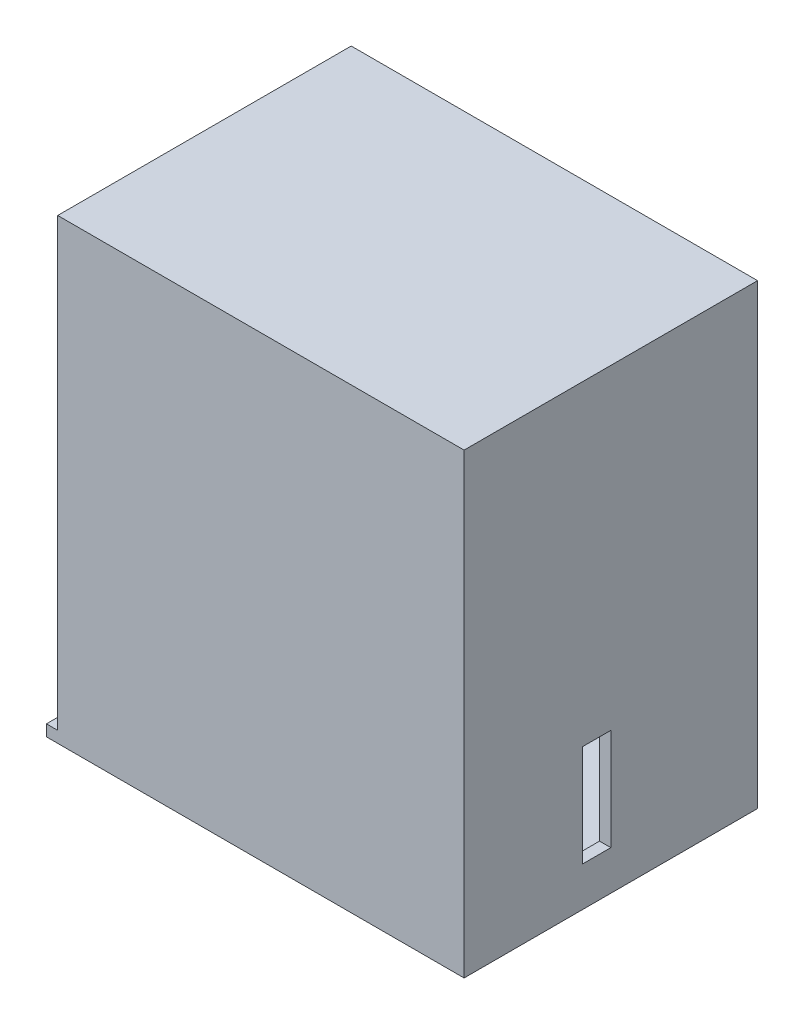
from build123d import *

# Parameters (mm, degrees)
SKIZZE1_W                       = 70
SKIZZE1_H                       = 77
AUFSATZ_LINEAR_AUSTRAGEN1_DEPTH = 2
SKIZZE2_W                       = 52
SKIZZE2_H                       = 77
SKIZZE2_W_2                     = 5
SKIZZE2_H_2                     = 18
AUFSATZ_LINEAR_AUSTRAGEN2_DEPTH = 2
SKIZZE3_W                       = 74
SKIZZE3_H                       = 52
SKIZZE3_W_2                     = 28
SKIZZE3_H_2                     = 6
AUFSATZ_LINEAR_AUSTRAGEN3_DEPTH = 2
SKIZZE9_W                       = 72
SKIZZE9_H                       = 52
AUFSATZ_LINEAR_AUSTRAGEN7_DEPTH = 2


with BuildPart() as part:
    # Skizze1 → Aufsatz-Linear austragen1 (new body)
    with BuildSketch(Plane.XY):
        with Locations((-44.446663724, -34.290378007)):
            Rectangle(SKIZZE1_W, SKIZZE1_H)
    extrude(amount=AUFSATZ_LINEAR_AUSTRAGEN1_DEPTH)

    # Skizze2 → Aufsatz-Linear austragen2 (add)
    with BuildSketch(Plane(origin=(-9.446663724, 0, 0), x_dir=(0, 0, -1), z_dir=(1, 0, 0))):
        with Locations((24, -34.290378007)):
            Rectangle(SKIZZE2_W, SKIZZE2_H)
        with Locations((21.5, -58.790378007)):
            Rectangle(SKIZZE2_W_2, SKIZZE2_H_2, mode=Mode.SUBTRACT)
    extrude(amount=AUFSATZ_LINEAR_AUSTRAGEN2_DEPTH)

    # Skizze3 → Aufsatz-Linear austragen3 (add)
    with BuildSketch(Plane.XZ.offset(72.790378007)):
        with Locations((-44.446663724, -24)):
            Rectangle(SKIZZE3_W, SKIZZE3_H)
        with Locations((-59.397812879, -32)):
            Rectangle(SKIZZE3_W_2, SKIZZE3_H_2, mode=Mode.SUBTRACT)
    extrude(amount=AUFSATZ_LINEAR_AUSTRAGEN3_DEPTH)

    # Skizze9 → Aufsatz-Linear austragen7 (add)
    with BuildSketch(Plane(origin=(0, 4.209621993, 0), x_dir=(1, 0, 0), z_dir=(0, 1, 0))):
        with Locations((-43.446663724, 24)):
            Rectangle(SKIZZE9_W, SKIZZE9_H)
    extrude(amount=AUFSATZ_LINEAR_AUSTRAGEN7_DEPTH)


solid = part.part
